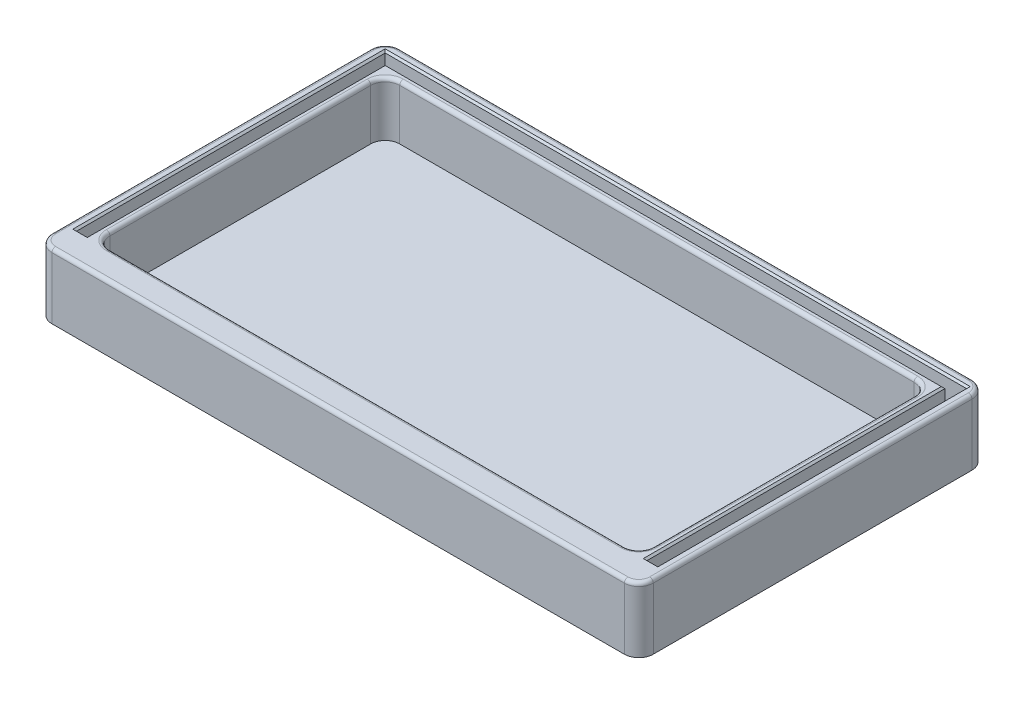
from build123d import *

# Parameters (mm, degrees)
SKETCH1_W           = 166
SKETCH1_H           = 96
BOSS_EXTRUDE1_DEPTH = 18
SKETCH2_W           = 150
SKETCH2_H           = 80
CUT_EXTRUDE1_DEPTH  = 15
CUT_EXTRUDE5_DEPTH  = 10
FILLET1_R           = 4
FILLET2_R           = 4
FILLET5_R           = 1
CHAMFER1_SIZE       = 0.5


with BuildPart() as part:
    # Sketch1 → Boss-Extrude1 (new body)
    with BuildSketch(Plane(origin=(0, 0, 0), x_dir=(1, 0, 0), z_dir=(0, 1, 0))):
        with Locations((18.075570249, -18.706715624)):
            Rectangle(SKETCH1_W, SKETCH1_H)
    extrude(amount=BOSS_EXTRUDE1_DEPTH)

    # Sketch2 → Cut-Extrude1 (cut)
    with BuildSketch(Plane(origin=(0, 18, 0), x_dir=(1, 0, 0), z_dir=(0, 1, 0))):
        with Locations((18.075570249, -18.706715624)):
            Rectangle(SKETCH2_W, SKETCH2_H)
    extrude(amount=-CUT_EXTRUDE1_DEPTH, mode=Mode.SUBTRACT)

    # Sketch9 → Cut-Extrude5 (cut)
    with BuildSketch(Plane(origin=(0, 18, 0), x_dir=(1, 0, 0), z_dir=(0, 1, 0))):
        Polygon((-62.174429751, 26.543284376), (98.325570249, 26.543284376), (98.325570249, -58.706715624), (95.325570249, -58.706715624), (95.325570249, 23.543284376), (-59.174429751, 23.543284376), (-59.174429751, -58.706715624), (-62.174429751, -58.706715624), align=None)
    extrude(amount=-CUT_EXTRUDE5_DEPTH, mode=Mode.SUBTRACT)

    # Fillet1
    fillet1_edges = [part.edges().sort_by_distance(p)[0] for p in [
        (-64.924429751, 9, -29.293284376),
        (101.075570249, 9, -29.293284376),
        (101.075570249, 9, 66.706715624),
        (-64.924429751, 9, 66.706715624),
    ]]
    fillet(fillet1_edges, radius=FILLET1_R)

    # Fillet2
    fillet2_edges = [part.edges().sort_by_distance(p)[0] for p in [
        (-56.924429751, 10.5, 58.706715624),
        (-56.924429751, 10.5, -21.293284376),
        (93.075570249, 10.5, -21.293284376),
        (93.075570249, 10.5, 58.706715624),
    ]]
    fillet(fillet2_edges, radius=FILLET2_R)

    # Fillet5
    fillet5_edges = [part.edges().sort_by_distance(p)[0] for p in [
        (-64.924429751, 18, 18.706715624),
        (18.075570249, 18, -29.293284376),
        (18.075570249, 18, 66.706715624),
        (101.075570249, 18, 18.706715624),
        (-63.752856875, 18, 65.535142749),
        (99.903997374, 18, 65.535142749),
        (99.903997374, 18, -28.1217115),
        (-63.752856875, 18, -28.1217115),
        (93.075570249, 18, 18.706715624),
        (18.075570249, 18, 58.706715624),
        (18.075570249, 18, -21.293284376),
        (-56.924429751, 18, 18.706715624),
        (91.903997374, 18, 57.535142749),
        (91.903997374, 18, -20.1217115),
        (-55.752856875, 18, -20.1217115),
        (-55.752856875, 18, 57.535142749),
    ]]
    fillet(fillet5_edges, radius=FILLET5_R)

    # Chamfer1
    chamfer1_edges = [part.edges().sort_by_distance(p)[0] for p in [
        (-62.174429751, 18, 16.081715624),
        (-60.674429751, 18, 58.706715624),
        (-59.174429751, 18, 17.581715624),
        (18.075570249, 18, -23.543284376),
        (95.325570249, 18, 17.581715624),
        (96.825570249, 18, 58.706715624),
        (98.325570249, 18, 16.081715624),
        (18.075570249, 18, -26.543284376),
    ]]
    chamfer(chamfer1_edges, length=CHAMFER1_SIZE)


solid = part.part
